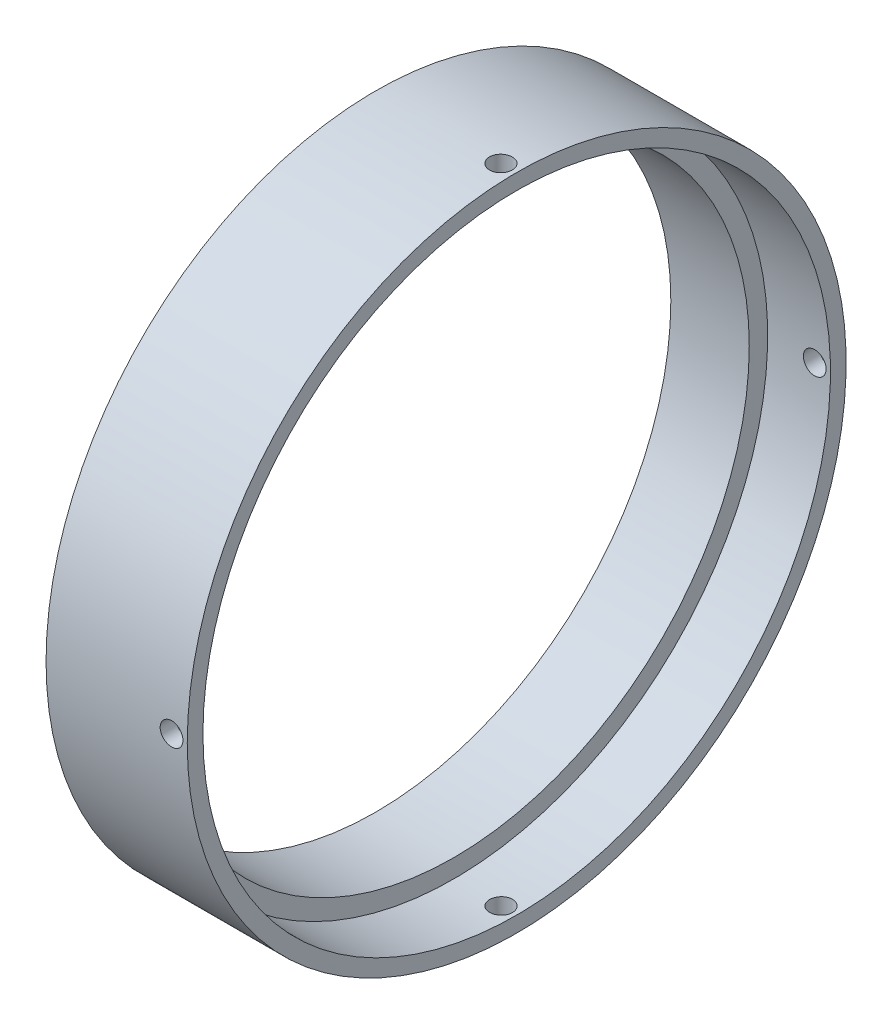
from build123d import *

# Parameters (mm, degrees)
D_GAGEMENT_M2_51_D           = 2.9
R_P_TITION_CIRCULAIRE1_COUNT = 2
R_P_TITION_CIRCULAIRE1_ANGLE = 90


with BuildPart() as part:
    # Esquisse1 → Révolution1 (revolve)
    with BuildSketch(Plane.XY):
        Polygon((0, 42), (0, 37.65), (10, 37.65), (10, 40), (18, 40), (18, 42), align=None)
    revolve(axis=Axis((-19.427138361, 0, 0), (1, 0, 0)))

    # Dégagement M2.51 (through all)
    with Locations(Plane(origin=(16, 42, 0), x_dir=(0, 0, 1), z_dir=(0, 1, 0))):
        with Locations((0, 0)):
            d_gagement_m2_51 = Hole(D_GAGEMENT_M2_51_D / 2)

    # Répétition circulaire1: Dégagement M2.51 ×2 about axis
    r_p_tition_circulaire1_axis = Axis((0, 0, 0), (-1, 0, 0))
    for i in range(1, R_P_TITION_CIRCULAIRE1_COUNT):
        add(d_gagement_m2_51.rotate(r_p_tition_circulaire1_axis, i * R_P_TITION_CIRCULAIRE1_ANGLE / (R_P_TITION_CIRCULAIRE1_COUNT - 1)), mode=Mode.SUBTRACT)


solid = part.part
